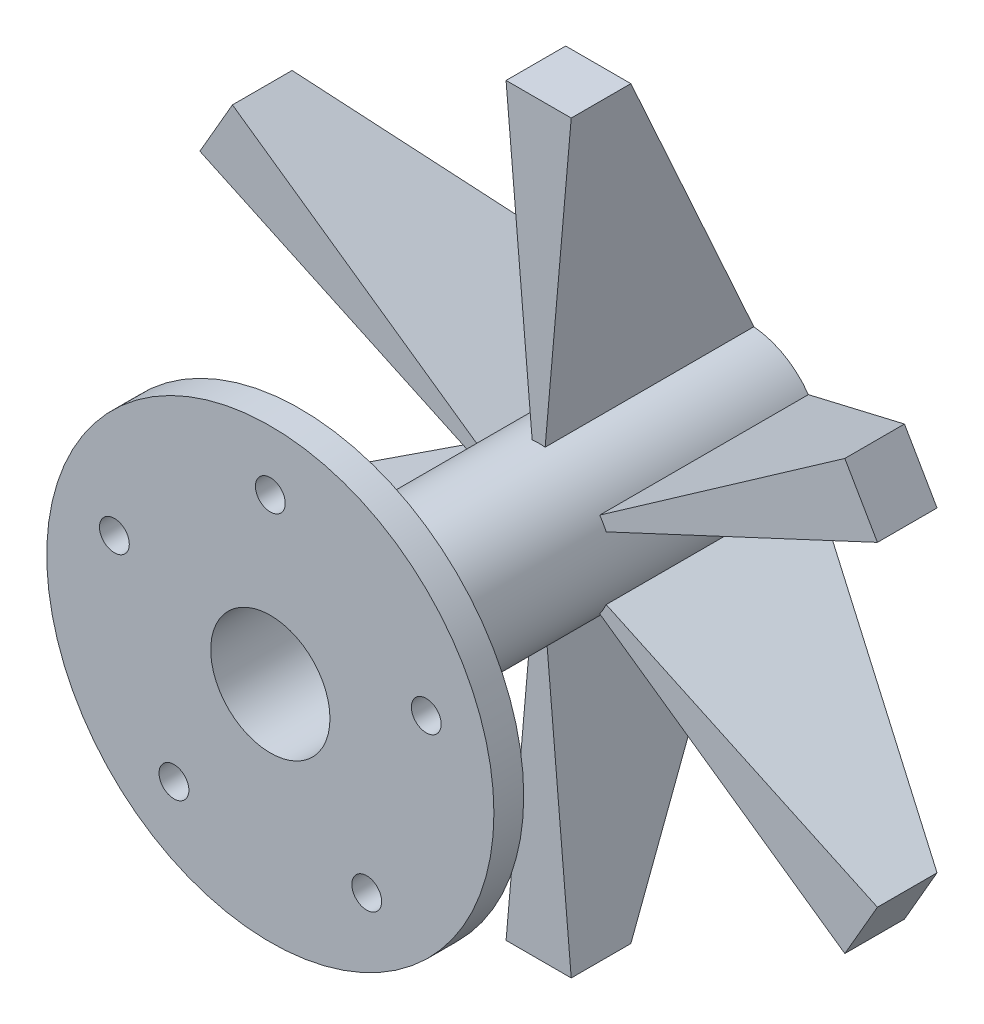
from build123d import *

# Parameters (mm, degrees)
SKETCH1_R                     = 75
SKETCH1_R_2                   = 5
BOSS_EXTRUDE1_DEPTH           = 10
SKETCH2_R                     = 25
BOSS_EXTRUDE2_DEPTH           = 150
BOSS_EXTRUDE3_DEPTH           = 70
CHAMFER2_SIZE                 = 100
CHAMFER2_SIZE2                = 50
CIRPATTERN3_COUNT             = 6
CHAMFER2_OF_CIRPATTERN3_SIZE2 = 50
CHAMFER2_OF_CIRPATTERN3_SIZE  = 100
SKETCH4_R                     = 20
CUT_EXTRUDE1_DEPTH            = 1
CUT_EXTRUDE1_DEPTH_BACK       = 161


with BuildPart() as part:
    # Sketch1 → Boss-Extrude1 (new body)
    with BuildSketch(Plane.XY):
        Circle(SKETCH1_R)
        with Locations((0, 55)):
            Circle(SKETCH1_R_2, mode=Mode.SUBTRACT)
        with Locations((52.308108396, 16.995934691)):
            Circle(SKETCH1_R_2, mode=Mode.SUBTRACT)
        with Locations((32.328188876, -44.495934691)):
            Circle(SKETCH1_R_2, mode=Mode.SUBTRACT)
        with Locations((-32.328188876, -44.495934691)):
            Circle(SKETCH1_R_2, mode=Mode.SUBTRACT)
        with Locations((-52.308108396, 16.995934691)):
            Circle(SKETCH1_R_2, mode=Mode.SUBTRACT)
    extrude(amount=BOSS_EXTRUDE1_DEPTH)

    # Sketch2 → Boss-Extrude2 (add)
    with BuildSketch(Plane(origin=(0, 0, 0), x_dir=(-1, 0, 0), z_dir=(0, 0, -1))):
        Circle(SKETCH2_R)
    extrude(amount=BOSS_EXTRUDE2_DEPTH)

    # Sketch3 → Boss-Extrude3 (add)
    with BuildSketch(Plane(origin=(0, 0, -150), x_dir=(-1, 0, 0), z_dir=(0, 0, -1))):
        with BuildLine():
            ThreePointArc((-2.178893569, 24.904867452), (0, 25), (2.178893569, 24.904867452))
            Line((2.178893569, 24.904867452), (10.927759921, 124.904867452))
            Line((10.927759921, 124.904867452), (-10.927759921, 124.904867452))
            Line((-10.927759921, 124.904867452), (-2.178893569, 24.904867452))
        make_face()
    boss_extrude3 = extrude(amount=-BOSS_EXTRUDE3_DEPTH)

    # Chamfer2
    chamfer2_edges = [part.edges().sort_by_distance(p)[0] for p in [
        (0, 124.904867452, -150),
    ]]
    chamfer2_side = [part.faces().sort_by_distance(p)[0] for p in [
        (0, 34.439140916, -150),
    ]]
    chamfer(chamfer2_edges, length=CHAMFER2_SIZE, length2=CHAMFER2_SIZE2, reference=chamfer2_side[0])

    # CirPattern3: Boss-Extrude3 ×6 about axis
    cirpattern3_axis = Axis((0, 0, 0), (0, 0, 1))
    for i in range(1, CIRPATTERN3_COUNT):
        add(boss_extrude3.rotate(cirpattern3_axis, i * 360 / CIRPATTERN3_COUNT))

    # Chamfer2 of CirPattern3
    chamfer2_of_cirpattern3_edges = [part.edges().sort_by_distance(p)[0] for p in [
        (-108.17078827, 62.452433726, -150),
        (-108.17078827, -62.452433726, -150),
        (0, -124.904867452, -150),
        (108.17078827, -62.452433726, -150),
        (108.17078827, 62.452433726, -150),
    ]]
    chamfer(chamfer2_of_cirpattern3_edges, length=CHAMFER2_OF_CIRPATTERN3_SIZE, length2=CHAMFER2_OF_CIRPATTERN3_SIZE2)

    # Sketch4 → Cut-Extrude1 (cut, two sides)
    with BuildSketch(Plane.XY.offset(10)) as cut_extrude1_sk:
        Circle(SKETCH4_R)
    extrude(amount=CUT_EXTRUDE1_DEPTH, mode=Mode.SUBTRACT)
    extrude(cut_extrude1_sk.sketch, amount=-CUT_EXTRUDE1_DEPTH_BACK, mode=Mode.SUBTRACT)


solid = part.part
